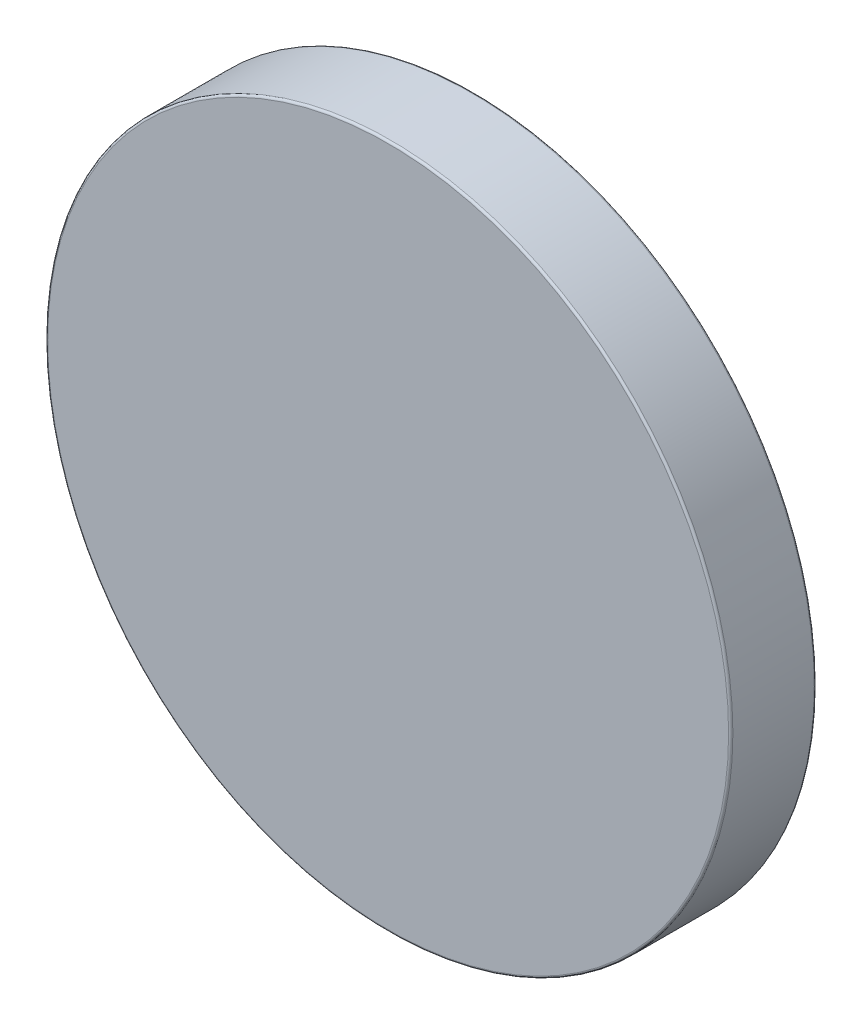
from build123d import *

# Parameters (mm, degrees)
SKETCH3_R                = 12.7
BOSS_EXTRUDE1_DEPTH      = 1.5875
BOSS_EXTRUDE1_DEPTH_BACK = 1.5875
FILLET1_R                = 0.079375


with BuildPart() as part:
    # Sketch3 → Boss-Extrude1 (new body, two sides)
    with BuildSketch(Plane.XY) as boss_extrude1_sk:
        Circle(SKETCH3_R)
    extrude(amount=BOSS_EXTRUDE1_DEPTH)
    extrude(boss_extrude1_sk.sketch, amount=-BOSS_EXTRUDE1_DEPTH_BACK)

    # Fillet1
    fillet1_edges = [part.edges().sort_by_distance(p)[0] for p in [
        (-12.7, 0, -1.5875),
        (-12.7, 0, 1.5875),
    ]]
    fillet(fillet1_edges, radius=FILLET1_R)


solid = part.part
